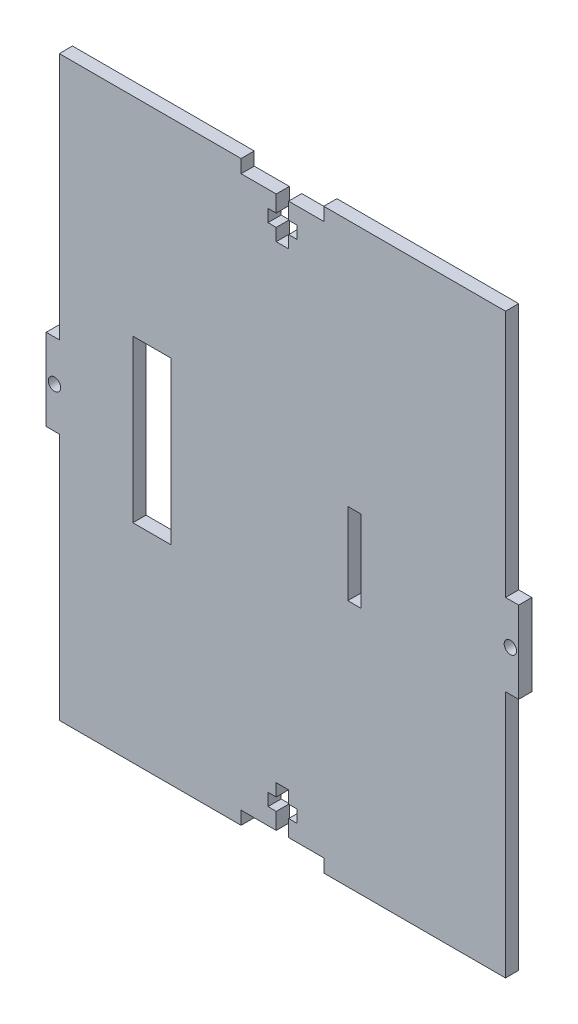
from build123d import *

# Parameters (mm, degrees)
SKETCH1_W           = 114.3
SKETCH1_H           = 139.7
BOSS_EXTRUDE1_DEPTH = 3.18
SKETCH2_R           = 1.5
SKETCH2_W           = 3.18
SKETCH2_H           = 59.975
CUT_EXTRUDE1_DEPTH  = 4.18
SKETCH3_W           = 3.18
SKETCH3_H           = 19.75
CUT_EXTRUDE2_DEPTH  = 3.18
SKETCH4_W           = 9.210739152
SKETCH4_H           = 39.093434174
CUT_EXTRUDE3_DEPTH  = 3.18


with BuildPart() as part:
    # Sketch1 → Boss-Extrude1 (new body)
    with BuildSketch(Plane.XY):
        Rectangle(SKETCH1_W, SKETCH1_H)
    extrude(amount=BOSS_EXTRUDE1_DEPTH)

    # Sketch2 → Cut-Extrude1 (cut, through all)
    with BuildSketch(Plane.XY.offset(3.18)):
        with Locations((-55.15, 0)):
            Circle(SKETCH2_R)
        with Locations((55.15, 0)):
            Circle(SKETCH2_R)
        Polygon((-10, 69.85), (10, 69.85), (10, 66.67), (1.5, 66.67), (1.5, 62.67), (3.5, 62.67), (3.5, 59.67), (1.5, 59.67), (1.5, 56.67), (-1.5, 56.67), (-1.5, 59.67), (-3.5, 59.67), (-3.5, 62.67), (-1.5, 62.67), (-1.5, 66.67), (-10, 66.67), align=None)
        Polygon((-10, -69.85), (-10, -66.67), (-1.5, -66.67), (-1.5, -62.67), (-3.5, -62.67), (-3.5, -59.67), (-1.5, -59.67), (-1.5, -56.67), (1.5, -56.67), (1.5, -59.67), (3.5, -59.67), (3.5, -62.67), (1.5, -62.67), (1.5, -66.67), (10, -66.67), (10, -69.85), align=None)
        with Locations((-55.56, 39.8625)):
            Rectangle(SKETCH2_W, SKETCH2_H)
        with Locations((-55.56, -39.8625)):
            Rectangle(SKETCH2_W, SKETCH2_H)
        with Locations((55.56, -39.8625)):
            Rectangle(SKETCH2_W, SKETCH2_H)
        with Locations((55.56, 39.8625)):
            Rectangle(SKETCH2_W, SKETCH2_H)
    extrude(amount=-CUT_EXTRUDE1_DEPTH, mode=Mode.SUBTRACT)

    # Sketch3 → Cut-Extrude2 (cut)
    with BuildSketch(Plane(origin=(0, 0, 0), x_dir=(-1, 0, 0), z_dir=(0, 0, -1))):
        with Locations((-17.401387583, 0)):
            Rectangle(SKETCH3_W, SKETCH3_H)
    extrude(amount=-CUT_EXTRUDE2_DEPTH, mode=Mode.SUBTRACT)

    # Sketch4 → Cut-Extrude3 (cut)
    with BuildSketch(Plane(origin=(0, 0, 0), x_dir=(-1, 0, 0), z_dir=(0, 0, -1))):
        with Locations((31.579688853, 0)):
            Rectangle(SKETCH4_W, SKETCH4_H)
    extrude(amount=-CUT_EXTRUDE3_DEPTH, mode=Mode.SUBTRACT)


solid = part.part
